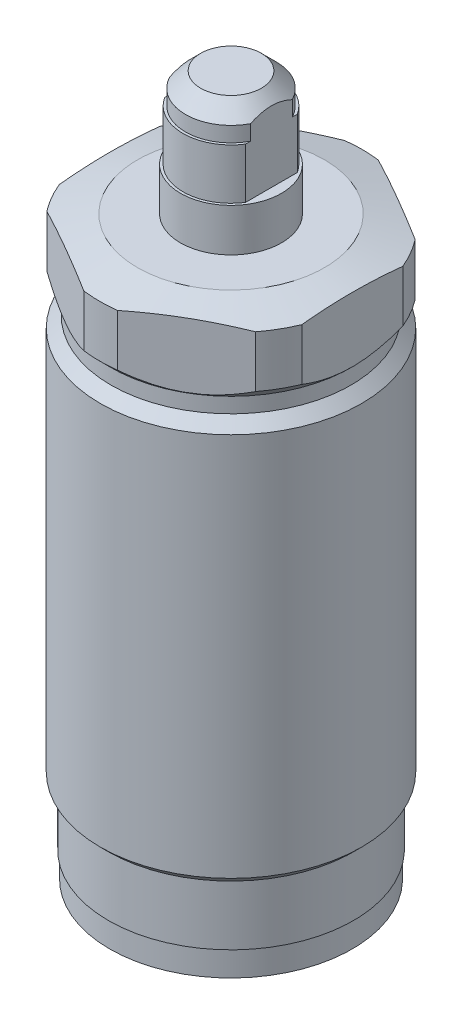
from build123d import *

# Parameters (mm, degrees)
SKETCH1_R          = 13
STOCK_DEPTH        = 27.25
HEX_HEAD_DEPTH     = 8.5
SKETCH5_R          = 12
RETAINER_DEPTH     = 2.5
SKETCH9_W          = 0.724432229
SKETCH9_H          = 3.174333178
SKETCH9_W_2        = 8
SKETCH9_H_2        = 0.600364256
SKETCH9_W_3        = 0.732916959
CUT_EXTRUDE3_DEPTH = 13.475
SKETCH10_R         = 5
EXTRUDE4_DEPTH     = 9.25
SKETCH13_R         = 5
SKETCH13_R_2       = 4.75
CUT_EXTRUDE4_DEPTH = 5
SKETCH14_W         = 1
SKETCH14_H         = 5
CUT_EXTRUDE5_DEPTH = 13.475


with BuildPart() as part:
    # Sketch1 → STOCK (new body, symmetric)
    with BuildSketch(Plane(origin=(0, 0, 0), x_dir=(1, 0, 0), z_dir=(0, 1, 0))):
        with Locations(Location((0, 0, 0), (0, 0, 270))):  # turned: the seam where the file's is
            Circle(SKETCH1_R)
    extrude(amount=STOCK_DEPTH, both=True)

    # Sketch2 → HEX_HEAD (cut)
    with BuildSketch(Plane(origin=(0, 27.25, 0), x_dir=(1, 0, 0), z_dir=(0, 1, 0))):
        with BuildLine():
            ThreePointArc((10.330127019, 7.892304845), (6.5, 11.258330249), (1.669872981, 12.892304845))
            Line((1.669872981, 12.892304845), (10.330127019, 7.892304845))
        make_face()
        with BuildLine():
            Line((-10.330127019, 7.892304845), (-1.669872981, 12.892304845))
            ThreePointArc((-1.669872981, 12.892304845), (-6.5, 11.258330249), (-10.330127019, 7.892304845))
        make_face()
        with BuildLine():
            Line((12, 5), (12, -5))
            ThreePointArc((12, -5), (13, 0), (12, 5))
        make_face()
        with BuildLine():
            Line((-12, -5), (-12, 5))
            ThreePointArc((-12, 5), (-13, 0), (-12, -5))
        make_face()
        with BuildLine():
            Line((10.330127019, -7.892304845), (1.669872981, -12.892304845))
            ThreePointArc((1.669872981, -12.892304845), (6.5, -11.258330249), (10.330127019, -7.892304845))
        make_face()
        with BuildLine():
            Line((-1.669872981, -12.892304845), (-10.330127019, -7.892304845))
            ThreePointArc((-10.330127019, -7.892304845), (-6.5, -11.258330249), (-1.669872981, -12.892304845))
        make_face()
    extrude(amount=-HEX_HEAD_DEPTH, mode=Mode.SUBTRACT)

    # Sketch3 → CROWN (revolve, cut)
    with BuildSketch(Plane.XY, mode=Mode.PRIVATE) as crown_sk:
        Polygon((9.25, 27.25), (13, 27.25), (13, 26.245190528), align=None)
    revolve(crown_sk.sketch.rotate(Axis((0, 0, 0), (0, 1, 0)), 97.380135052), axis=Axis((0, 0, 0), (0, 1, 0)), mode=Mode.SUBTRACT)  # turned: the seam where the file's is

    # Sketch4 → OD_PROFILE (revolve, cut)
    with BuildSketch(Plane.XY, mode=Mode.PRIVATE) as od_profile_sk:
        Polygon((17.017319953, -27.25), (17.017319953, 25.142319953), (11.875, 20), (11.875, 18.5), (12.925, 17.45), (12.925, -20.56), (12.125, -21.36), (12.125, -27.25), align=None)
    revolve(od_profile_sk.sketch.rotate(Axis((0, -29.172938247, 0), (0, 1, 0)), 90), axis=Axis((0, -29.172938247, 0), (0, 1, 0)), mode=Mode.SUBTRACT)  # turned: the seam where the file's is

    # Sketch5 → RETAINER (add)
    with BuildSketch(Plane.XZ.offset(27.25)):
        with Locations(Location((0, 0, 0), (0, 0, 90))):  # turned: the seam where the file's is
            Circle(SKETCH5_R)
    extrude(amount=RETAINER_DEPTH)



with BuildPart() as body_2:
    # Sketch8 → Revolve1 (revolve)
    with BuildSketch(Plane.XY, mode=Mode.PRIVATE) as revolve1_sk:
        Polygon((0, 39.5), (3, 39.5), (4.5, 38), (4.5, 36.5), (0, 36.5), align=None)
    revolve(revolve1_sk.sketch.rotate(Axis((0, 0, 0), (0, 1, 0)), 90), axis=Axis((0, 0, 0), (0, 1, 0)))  # turned: the seam where the file's is

    # Sketch9 → Cut-Extrude3 (cut, symmetric)
    with BuildSketch(Plane.XY):
        with Locations((4.362216115, 38.087166589)):
            Rectangle(SKETCH9_W, SKETCH9_H)
        with Locations((0, 36.199817872)):
            Rectangle(SKETCH9_W_2, SKETCH9_H_2)
        with Locations((-4.36645848, 38.087166589)):
            Rectangle(SKETCH9_W_3, SKETCH9_H)
    extrude(amount=CUT_EXTRUDE3_DEPTH, both=True, mode=Mode.SUBTRACT)


with BuildPart() as part_1:
    add(part.part)

    add(body_2.part)  # Extrude4 merges body 2
    # Sketch10 → Extrude4 (add)
    with BuildSketch(Plane(origin=(0, 27.25, 0), x_dir=(1, 0, 0), z_dir=(0, 1, 0))):
        with Locations(Location((0, 0, 0), (0, 0, 180))):  # turned: the seam where the file's is
            Circle(SKETCH10_R)
    extrude(amount=EXTRUDE4_DEPTH)

    # Sketch13 → Cut-Extrude4 (cut)
    with BuildSketch(Plane(origin=(0, 36.5, 0), x_dir=(1, 0, 0), z_dir=(0, 1, 0))):
        with Locations(Location((0, 0, 0), (0, 0, 180))):  # turned: the seam where the file's is
            Circle(SKETCH13_R)
        with Locations(Location((0, 0, 0), (0, 0, 180))):  # turned: the seam where the file's is
            Circle(SKETCH13_R_2, mode=Mode.SUBTRACT)
    extrude(amount=-CUT_EXTRUDE4_DEPTH, mode=Mode.SUBTRACT)

    # Sketch14 → Cut-Extrude5 (cut, symmetric)
    with BuildSketch(Plane.XY):
        with Locations((4.5, 34)):
            Rectangle(SKETCH14_W, SKETCH14_H)
        with Locations((-4.5, 34)):
            Rectangle(SKETCH14_W, SKETCH14_H)
    extrude(amount=CUT_EXTRUDE5_DEPTH, both=True, mode=Mode.SUBTRACT)


solid = part_1.part
